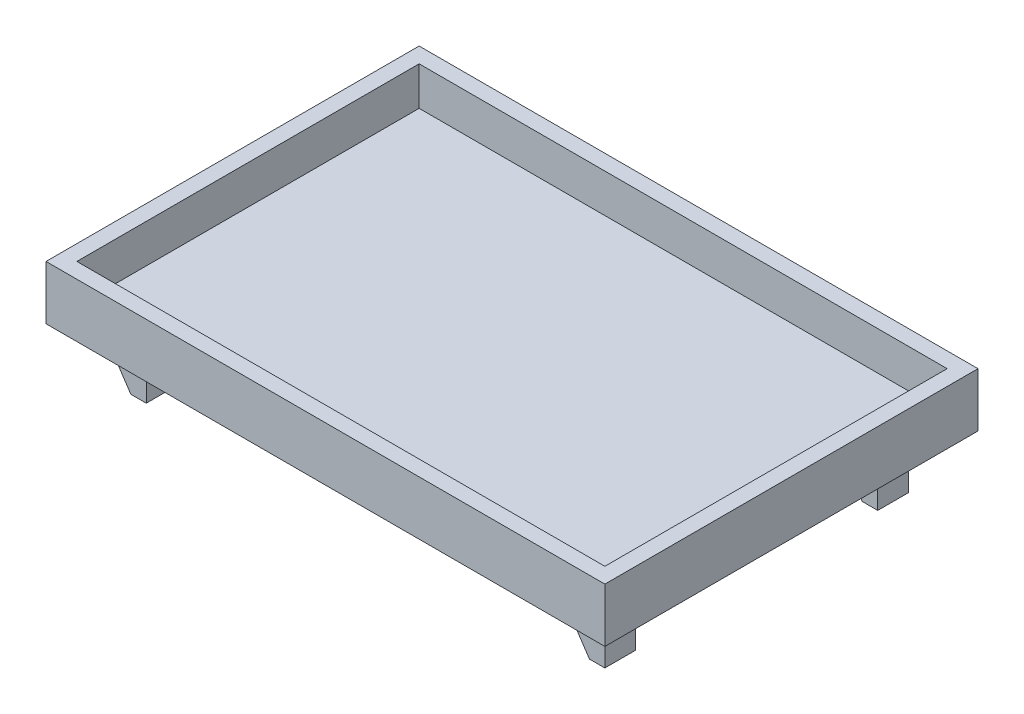
from build123d import *

# Parameters (mm, degrees)
SKETCH1_W           = 92.0242
SKETCH1_H           = 61.4426
BOSS_EXTRUDE1_DEPTH = 8.89
SKETCH2_W           = 86.9442
SKETCH2_H           = 56.3626
CUT_EXTRUDE4_DEPTH  = 6.35
SKETCH3_W           = 5.08
SKETCH3_H           = 5.08
BOSS_EXTRUDE2_DEPTH = 8.7884
CUT_EXTRUDE5_DEPTH  = 5.08


with BuildPart() as part:
    # Sketch1 → Boss-Extrude1 (new body)
    with BuildSketch(Plane(origin=(0, 0, 0), x_dir=(1, 0, 0), z_dir=(0, 1, 0))):
        Rectangle(SKETCH1_W, SKETCH1_H)
    extrude(amount=-BOSS_EXTRUDE1_DEPTH)

    # Sketch2 → Cut-Extrude4 (cut)
    with BuildSketch(Plane(origin=(0, 0, 0), x_dir=(1, 0, 0), z_dir=(0, 1, 0))):
        Rectangle(SKETCH2_W, SKETCH2_H)
    extrude(amount=-CUT_EXTRUDE4_DEPTH, mode=Mode.SUBTRACT)

    # Sketch3 → Boss-Extrude2 (add)
    with BuildSketch(Plane.XZ.offset(8.89)):
        with Locations((37.7571, -22.4663)):
            Rectangle(SKETCH3_W, SKETCH3_H)
        with Locations((-37.7571, 22.4663)):
            Rectangle(SKETCH3_W, SKETCH3_H)
        with Locations((-37.7571, -22.4663)):
            Rectangle(SKETCH3_W, SKETCH3_H)
        with Locations((37.7571, 22.4663)):
            Rectangle(SKETCH3_W, SKETCH3_H)
    extrude(amount=BOSS_EXTRUDE2_DEPTH)

    # Sketch4 → Cut-Extrude5 (cut)
    with BuildSketch(Plane.XY.offset(25.0063)):
        Polygon((35.2171, -13.876876095), (35.2171, -17.6784), (37.7571, -17.6784), align=None)
        Polygon((35.2171, -8.89), (35.2171, -12.606876095), (36.938174553, -12.068216701), (36.938174553, -8.89), align=None)
        Polygon((-37.7571, -17.6784), (-40.2971, -13.876876095), (-40.2971, -17.6784), align=None)
        Polygon((-38.576025447, -12.068216701), (-38.576025447, -8.89), (-40.2971, -8.89), (-40.2971, -12.606876095), align=None)
    cut_extrude5 = extrude(amount=-CUT_EXTRUDE5_DEPTH, mode=Mode.SUBTRACT)

    # Mirror1: Cut-Extrude5 across plane
    add(cut_extrude5.mirror(Plane.XY), mode=Mode.SUBTRACT)


solid = part.part
